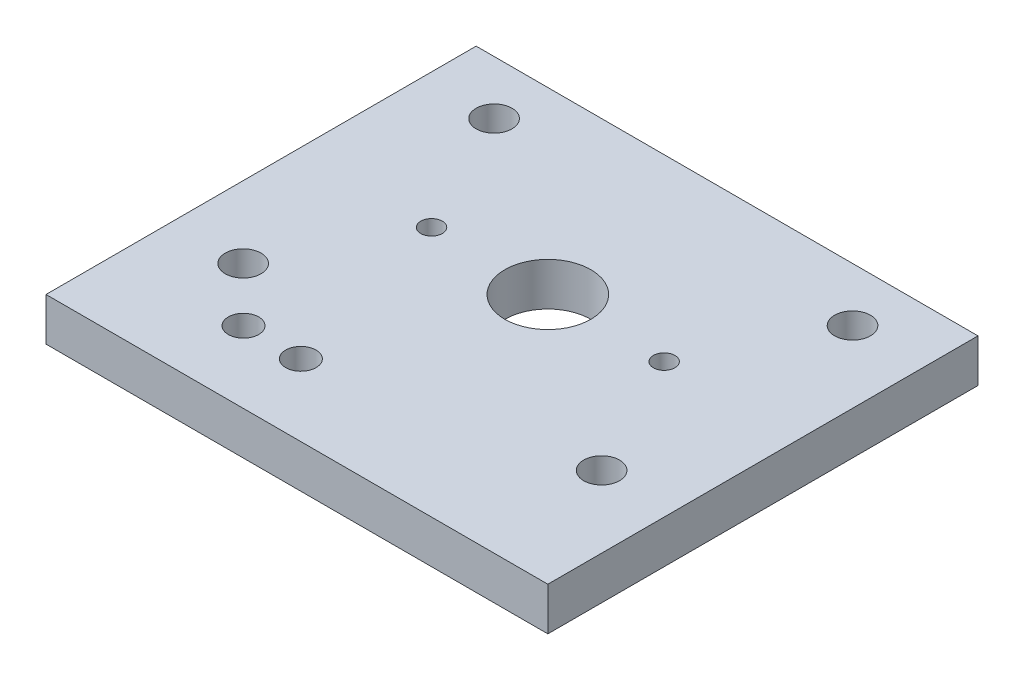
from build123d import *

# Parameters (mm, degrees)
SKETCH1_W           = 70
SKETCH1_H           = 60
SKETCH1_R           = 2.125
SKETCH1_R_2         = 2.5
SKETCH1_R_3         = 1.5
SKETCH1_R_4         = 6
BOSS_EXTRUDE1_DEPTH = 6


with BuildPart() as part:
    # Sketch1 → Boss-Extrude1 (new body)
    with BuildSketch(Plane(origin=(0, 0, 0), x_dir=(1, 0, 0), z_dir=(0, 1, 0))):
        with Locations((0, -5)):
            Rectangle(SKETCH1_W, SKETCH1_H)
        with Locations((-9.450109616, -25)):
            Circle(SKETCH1_R, mode=Mode.SUBTRACT)
        with Locations((-17.450109616, -25)):
            Circle(SKETCH1_R, mode=Mode.SUBTRACT)
        with Locations((-25, -17.5)):
            Circle(SKETCH1_R_2, mode=Mode.SUBTRACT)
        with Locations((25, -17.5)):
            Circle(SKETCH1_R_2, mode=Mode.SUBTRACT)
        with Locations((-16.22, 0)):
            Circle(SKETCH1_R_3, mode=Mode.SUBTRACT)
        Circle(SKETCH1_R_4, mode=Mode.SUBTRACT)
        with Locations((-25, 17.5)):
            Circle(SKETCH1_R_2, mode=Mode.SUBTRACT)
        with Locations((16.22, 0)):
            Circle(SKETCH1_R_3, mode=Mode.SUBTRACT)
        with Locations((25, 17.5)):
            Circle(SKETCH1_R_2, mode=Mode.SUBTRACT)
    extrude(amount=BOSS_EXTRUDE1_DEPTH)


solid = part.part
